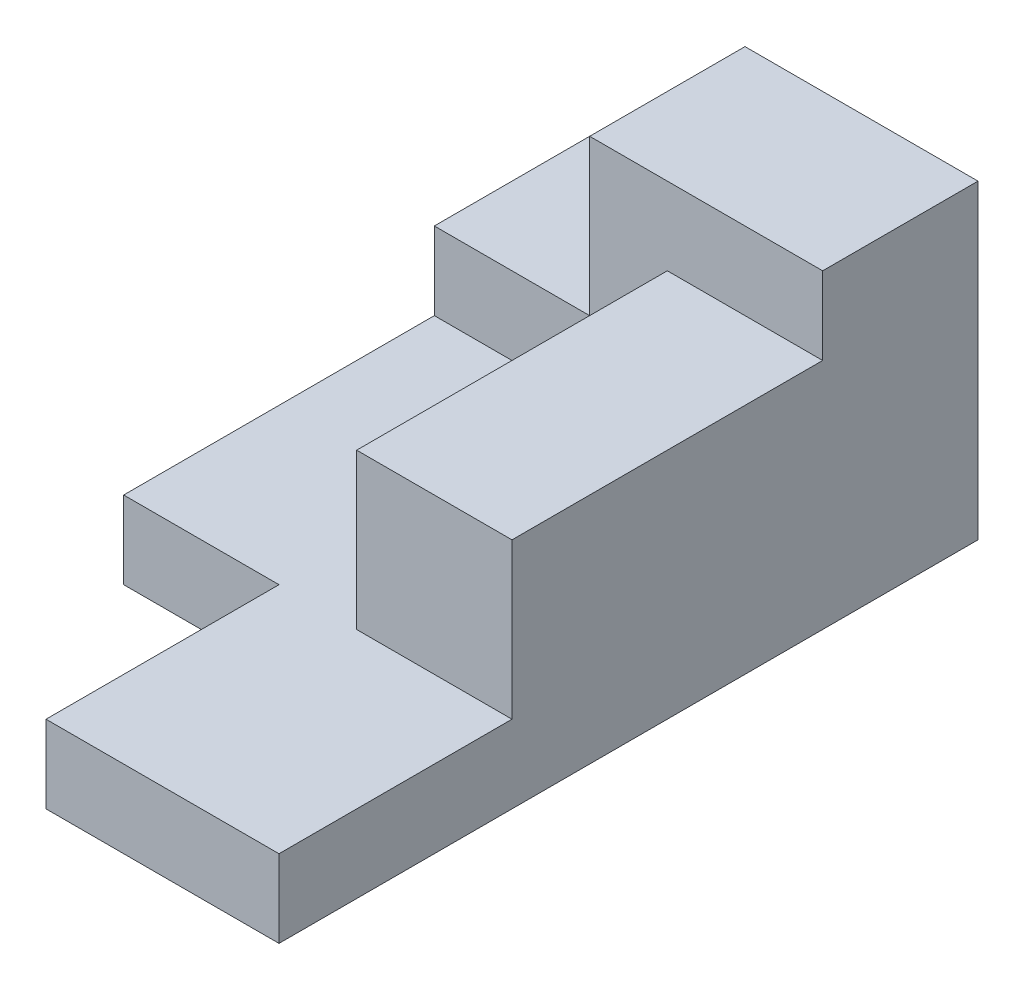
from build123d import *

# Parameters (mm, degrees)
SKETCH1_W               = 50
SKETCH1_H               = 90
BOSS_EXTRUDE1_DEPTH     = 10
SKETCH2_W               = 20
SKETCH2_H               = 30
CUT_EXTRUDE1_DEPTH      = 1
CUT_EXTRUDE1_DEPTH_BACK = 11
SKETCH5_W               = 50
SKETCH5_H               = 20
BOSS_EXTRUDE3_DEPTH     = 10
SKETCH6_W               = 30
SKETCH6_H               = 20
BOSS_EXTRUDE4_DEPTH     = 20
SKETCH7_W               = 20
SKETCH7_H               = 40
BOSS_EXTRUDE5_DEPTH     = 20


with BuildPart() as part:
    # Sketch1 → Boss-Extrude1 (new body)
    with BuildSketch(Plane(origin=(0, 0, 0), x_dir=(1, 0, 0), z_dir=(0, 1, 0))):
        with Locations((-5.23255814, -21.162790698)):
            Rectangle(SKETCH1_W, SKETCH1_H)
    extrude(amount=BOSS_EXTRUDE1_DEPTH)

    # Sketch2 → Cut-Extrude1 (cut, two sides)
    with BuildSketch(Plane(origin=(0, 10, 0), x_dir=(1, 0, 0), z_dir=(0, 1, 0))) as cut_extrude1_sk:
        with Locations((-20.23255814, -51.162790698)):
            Rectangle(SKETCH2_W, SKETCH2_H)
    extrude(amount=CUT_EXTRUDE1_DEPTH, mode=Mode.SUBTRACT)
    extrude(cut_extrude1_sk.sketch, amount=-CUT_EXTRUDE1_DEPTH_BACK, mode=Mode.SUBTRACT)

    # Sketch5 → Boss-Extrude3 (add)
    with BuildSketch(Plane(origin=(0, 10, 0), x_dir=(1, 0, 0), z_dir=(0, 1, 0))):
        with Locations((-5.23255814, 13.837209302)):
            Rectangle(SKETCH5_W, SKETCH5_H)
    extrude(amount=BOSS_EXTRUDE3_DEPTH)

    # Sketch6 → Boss-Extrude4 (add)
    with BuildSketch(Plane(origin=(0, 20, 0), x_dir=(1, 0, 0), z_dir=(0, 1, 0))):
        with Locations((4.76744186, 13.837209302)):
            Rectangle(SKETCH6_W, SKETCH6_H)
    extrude(amount=BOSS_EXTRUDE4_DEPTH)

    # Sketch7 → Boss-Extrude5 (add)
    with BuildSketch(Plane(origin=(0, 10, 0), x_dir=(1, 0, 0), z_dir=(0, 1, 0))):
        with Locations((9.76744186, -16.162790698)):
            Rectangle(SKETCH7_W, SKETCH7_H)
    extrude(amount=BOSS_EXTRUDE5_DEPTH)


solid = part.part
